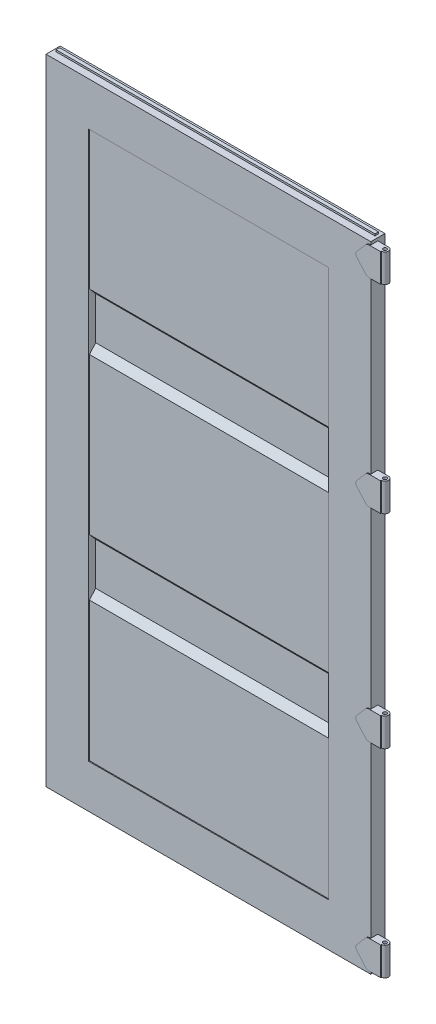
from build123d import *

# Parameters (mm, degrees)
SKETCH2_W             = 152.4
SKETCH2_H             = 50.8
SKETCH2_W_2           = 146.05
SKETCH2_H_2           = 44.45
BOSS_EXTRUDE1_DEPTH   = 1133.475
BOSS_EXTRUDE1_2_DEPTH = 1133.475
BOSS_EXTRUDE4_DEPTH   = 858.8375
SKETCH5_W             = 50.8
SKETCH5_H             = 6.35
BOSS_EXTRUDE5_DEPTH   = 1163.6375
BOSS_EXTRUDE6_DEPTH   = 858.8375
SKETCH7_W             = 101.6
SKETCH7_H             = 101.6
BOSS_EXTRUDE7_DEPTH   = 25.4
SKETCH1_W             = 1143
SKETCH1_H             = 19.05
BOSS_EXTRUDE8_DEPTH   = 12.7
BOSS_EXTRUDE9_DEPTH   = 3.175
SKETCH8_R             = 6.35
CUT_EXTRUDE1_DEPTH    = 2252.98


with BuildPart() as part:
    # Sketch2 → Boss-Extrude1 (new body, symmetric)
    with BuildSketch(Plane(origin=(0, 0, 0), x_dir=(1, 0, 0), z_dir=(0, 1, 0))):
        with Locations((-505.61875, 0)):
            Rectangle(SKETCH2_W, SKETCH2_H)
        with Locations((-505.61875, 0)):
            Rectangle(SKETCH2_W_2, SKETCH2_H_2, mode=Mode.SUBTRACT)
    extrude(amount=BOSS_EXTRUDE1_DEPTH, both=True)



with BuildPart() as body_2:
    # Sketch2 → Boss-Extrude1 2 (new body, symmetric)
    with BuildSketch(Plane(origin=(0, 0, 0), x_dir=(1, 0, 0), z_dir=(0, 1, 0))):
        with Locations((505.61875, 0)):
            Rectangle(SKETCH2_W, SKETCH2_H)
        with Locations((505.61875, 0)):
            Rectangle(SKETCH2_W_2, SKETCH2_H_2, mode=Mode.SUBTRACT)
    extrude(amount=BOSS_EXTRUDE1_2_DEPTH, both=True)


with BuildPart() as part_1:
    add(part.part)

    add(body_2.part)  # Boss-Extrude4 merges body 2
    # Sketch3 → Boss-Extrude4 (add)
    with BuildSketch(Plane.ZY.offset(-429.41875)):
        Polygon((19.05, 987.425), (0, 987.425), (0, 981.075), (25.4, 981.075), (25.4, 1133.475), (-25.4, 1133.475), (-25.4, 1127.125), (19.05, 1127.125), align=None)
        Polygon((-25.4, -1133.475), (25.4, -1133.475), (25.4, -981.075), (0, -981.075), (0, -987.425), (19.05, -987.425), (19.05, -1127.125), (-25.4, -1127.125), align=None)
    extrude(amount=BOSS_EXTRUDE4_DEPTH)

    # Sketch5 → Boss-Extrude5 (add)
    with BuildSketch(Plane.ZY.offset(581.81875)):
        with Locations((0, -1133.475)):
            Rectangle(SKETCH5_W, SKETCH5_H)
        with Locations((0, 1133.475)):
            Rectangle(SKETCH5_W, SKETCH5_H)
    extrude(amount=-BOSS_EXTRUDE5_DEPTH)

    # Sketch6 → Boss-Extrude6 (add)
    with BuildSketch(Plane(origin=(-429.41875, 0, 0), x_dir=(0, 0, -1), z_dir=(1, 0, 0))):
        Polygon((-15.875, -981.075), (-15.875, -482.6), (6.35, -457.2), (6.35, -304.8), (-15.875, -279.4), (-15.875, 279.4), (6.35, 304.8), (6.35, 457.2), (-15.875, 482.6), (-15.875, 981.075), (-22.225, 981.075), (-22.225, 482.6), (0, 457.2), (0, 304.8), (-22.225, 279.4), (-22.225, -279.4), (0, -304.8), (0, -457.2), (-22.225, -482.6), (-22.225, -981.075), align=None)
    extrude(amount=BOSS_EXTRUDE6_DEPTH)

    # Sketch7 → Boss-Extrude7 (add)
    with BuildSketch(Plane.XY.offset(25.4)):
        with Locations((584.2, 1075.69)):
            Rectangle(SKETCH7_W, SKETCH7_H)
        with Locations((584.2, 364.49)):
            Rectangle(SKETCH7_W, SKETCH7_H)
        with Locations((584.2, -364.49)):
            Rectangle(SKETCH7_W, SKETCH7_H)
        with Locations((584.2, -1075.69)):
            Rectangle(SKETCH7_W, SKETCH7_H)
    extrude(amount=-BOSS_EXTRUDE7_DEPTH)

    # Sketch1 → Boss-Extrude8 (add)
    with BuildSketch(Plane.XY):
        with Locations((0, -1133.475)):
            Rectangle(SKETCH1_W, SKETCH1_H)
        with Locations((0, 1133.475)):
            Rectangle(SKETCH1_W, SKETCH1_H)
    extrude(amount=-BOSS_EXTRUDE8_DEPTH)

    # Sketch9 → Boss-Extrude9 (add)
    with BuildSketch(Plane.XY.offset(25.4)):
        with BuildLine():
            Line((635, 1126.49), (635, 1024.89))
            Line((635, 1024.89), (579.538518777, 1024.89))
            ThreePointArc((579.538518777, 1024.89), (572.213815984, 1026.468854084), (566.189972237, 1030.925013611))
            Line((566.189972237, 1030.925013611), (534.1840739, 1067.300724008))
            ThreePointArc((534.1840739, 1067.300724008), (531.01875, 1075.69), (534.1840739, 1084.079275992))
            Line((534.1840739, 1084.079275992), (566.189972237, 1120.454986389))
            ThreePointArc((566.189972237, 1120.454986389), (572.213815984, 1124.911145916), (579.538518777, 1126.49))
            Line((579.538518777, 1126.49), (635, 1126.49))
        make_face()
        with BuildLine():
            Line((635, 415.29), (635, 313.69))
            Line((635, 313.69), (578.904878784, 313.69))
            ThreePointArc((578.904878784, 313.69), (571.5, 315.30534194), (565.440611797, 319.857854871))
            Line((565.440611797, 319.857854871), (534.101416438, 356.195610622))
            ThreePointArc((534.101416438, 356.195610622), (531.01875, 364.49), (534.101416438, 372.784389378))
            Line((534.101416438, 372.784389378), (565.440611797, 409.122145129))
            ThreePointArc((565.440611797, 409.122145129), (571.5, 413.67465806), (578.904878784, 415.29))
            Line((578.904878784, 415.29), (635, 415.29))
        make_face()
        with BuildLine():
            Line((635, -313.69), (635, -415.29))
            Line((635, -415.29), (578.904878784, -415.29))
            ThreePointArc((578.904878784, -415.29), (571.5, -413.67465806), (565.440611797, -409.122145129))
            Line((565.440611797, -409.122145129), (534.101416438, -372.784389378))
            ThreePointArc((534.101416438, -372.784389378), (531.01875, -364.49), (534.101416438, -356.195610622))
            Line((534.101416438, -356.195610622), (565.440611797, -319.857854871))
            ThreePointArc((565.440611797, -319.857854871), (571.5, -315.30534194), (578.904878784, -313.69))
            Line((578.904878784, -313.69), (635, -313.69))
        make_face()
        with BuildLine():
            Line((635, -1024.89), (635, -1126.49))
            Line((635, -1126.49), (578.904878784, -1126.49))
            ThreePointArc((578.904878784, -1126.49), (571.5, -1124.87465806), (565.440611797, -1120.322145129))
            Line((565.440611797, -1120.322145129), (534.101416438, -1083.984389378))
            ThreePointArc((534.101416438, -1083.984389378), (531.01875, -1075.69), (534.101416438, -1067.395610622))
            Line((534.101416438, -1067.395610622), (565.440611797, -1031.057854871))
            ThreePointArc((565.440611797, -1031.057854871), (571.5, -1026.50534194), (578.904878784, -1024.89))
            Line((578.904878784, -1024.89), (635, -1024.89))
        make_face()
    extrude(amount=BOSS_EXTRUDE9_DEPTH)

    # Sketch8 → Cut-Extrude1 (cut)
    with BuildSketch(Plane(origin=(0, 1126.49, 0), x_dir=(1, 0, 0), z_dir=(0, 1, 0))):
        with Locations((619.91875, -12.7)):
            Circle(SKETCH8_R)
        with BuildLine():
            Line((619.91875, 0), (635, 0))
            Line((635, 0), (635, -28.575))
            Line((635, -28.575), (619.91875, -28.575))
            Line((619.91875, -28.575), (619.91875, -25.4))
            ThreePointArc((619.91875, -25.4), (632.61875, -12.7), (619.91875, 0))
        make_face()
    extrude(amount=-CUT_EXTRUDE1_DEPTH, mode=Mode.SUBTRACT)


solid = part_1.part
